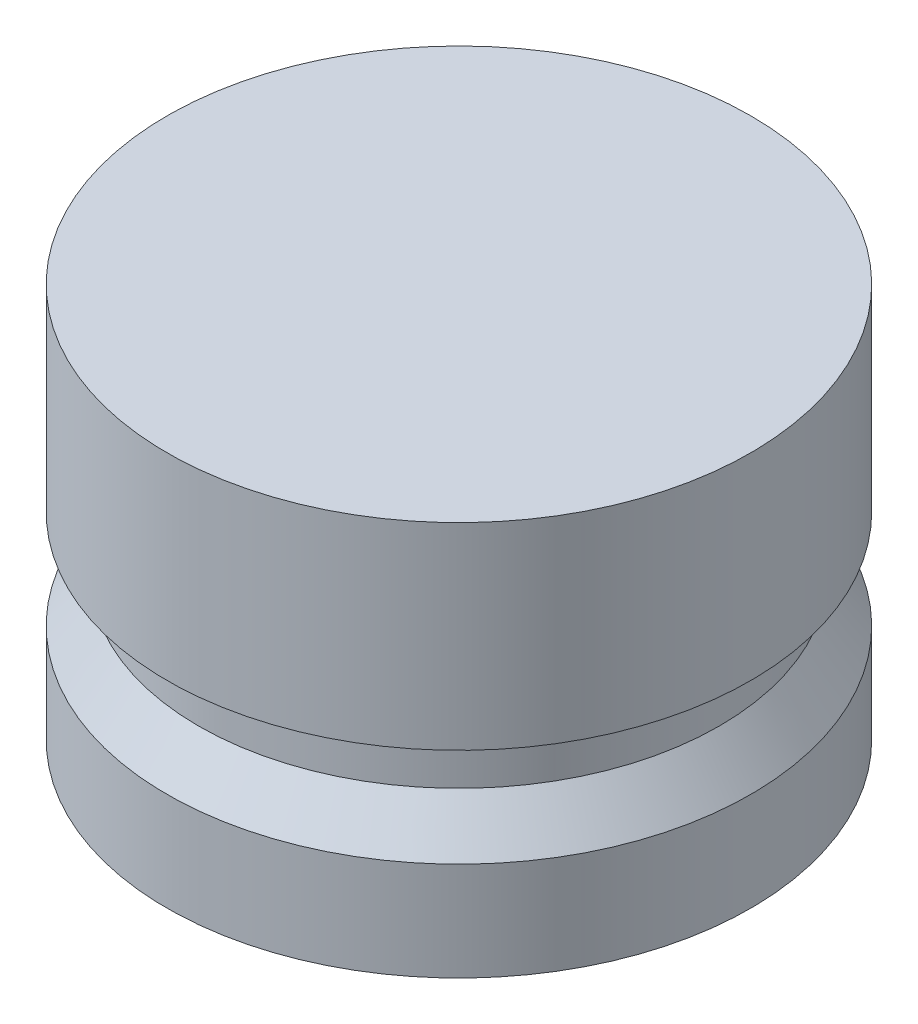
from build123d import *


with BuildPart() as part:
    # Sketch1 → Revolve1 (revolve)
    with BuildSketch(Plane.XY):
        Polygon((0, 0), (-9.398, 0), (-9.398, 3.175), (-8.382, 4.572), (-8.382, 6.35), (-9.398, 6.35), (-9.398, 12.7), (0, 12.7), align=None)
    revolve(axis=Axis((0, 0, 0), (0, 1, 0)))


solid = part.part
